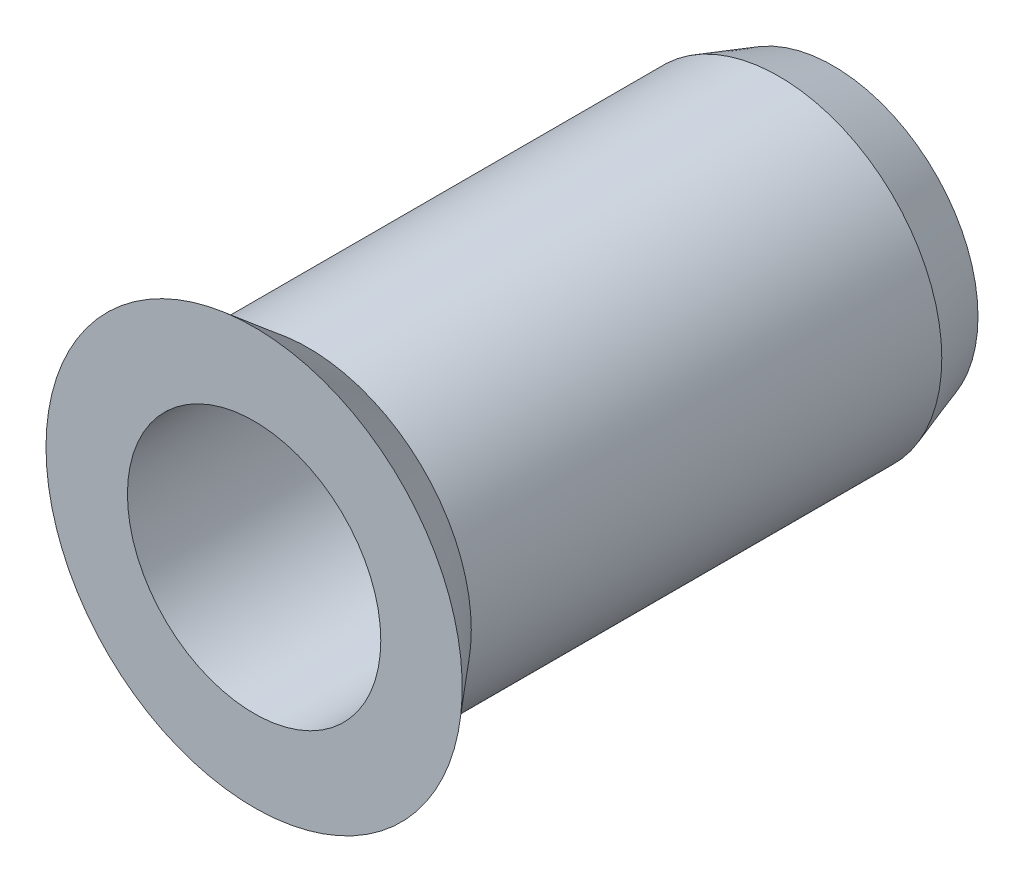
from build123d import *


with BuildPart() as part:
    # Эскиз1 → Повернуть1 (revolve)
    with BuildSketch(Plane.XZ):
        Polygon((3.5, 9), (2.500000001, 8.39913938), (2.500000001, 1.000000001), (3.500000001, 1e-09), (4.000000001, 1e-09), (4.500000001, 1.500000001), (4.500000001, 14.500000001), (5.75, 16.000000002), (3.5, 16.000000002), align=None)
    revolve(axis=Axis((0, 0, 16.000000001), (0, 0, -1)))


solid = part.part
